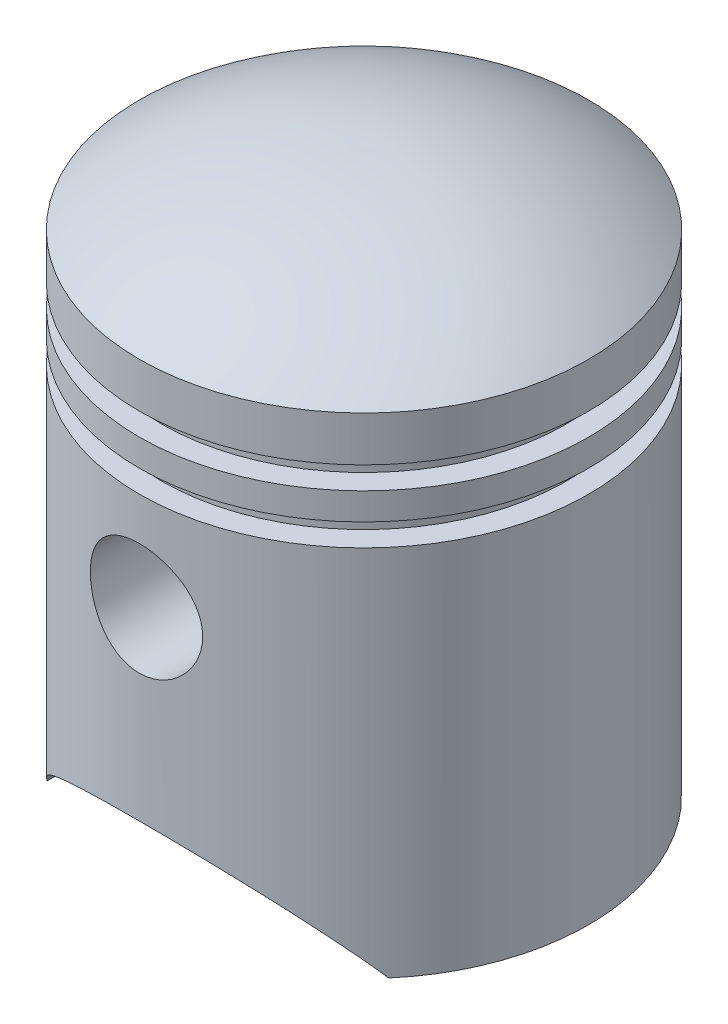
from build123d import *

# Parameters (mm, degrees)
SKETCH2_R               = 6.25
CUT_EXTRUDE1_DEPTH      = 26.0000001
CUT_EXTRUDE1_DEPTH_BACK = 26.0000001
BOSS_EXTRUDE2_START     = 12
SKETCH3_R               = 7.25
SKETCH3_R_2             = 6.25
BOSS_EXTRUDE2_DEPTH     = 11.925666


with BuildPart() as part:
    # Sketch1 → Revolve1 (revolve)
    with BuildSketch(Plane.XY):
        with BuildLine():
            Line((25, 0), (25, 41.5))
            Line((25, 41.5), (22.5, 41.5))
            Line((22.5, 41.5), (22.5, 44))
            Line((22.5, 44), (25, 44))
            Line((25, 44), (25, 47))
            Line((25, 47), (22.5, 47))
            Line((22.5, 47), (22.5, 49.5))
            Line((22.5, 49.5), (25, 49.5))
            Line((25, 49.5), (25, 54.5))
            ThreePointArc((25, 54.5), (13.174901691, 60.609067785), (0, 62.5))
            Line((0, 62.5), (0, 60.49936285))
            ThreePointArc((0, 60.49936285), (12.069492637, 58.859165445), (23, 53.484511145))
            Line((23, 53.484511145), (23, 51.5))
            Line((23, 51.5), (20.5, 51.5))
            Line((20.5, 51.5), (20.5, 45.5))
            Line((20.5, 45.5), (20.5, 39.5))
            Line((20.5, 39.5), (23, 39.5))
            Line((23, 39.5), (23, 0))
            Line((23, 0), (25, 0))
        make_face()
    revolve(axis=Axis((0, 62.5, 0), (0, -1, 0)))

    # Sketch2 → Cut-Extrude1 (cut, two sides)
    with BuildSketch(Plane.XY) as cut_extrude1_sk:
        with Locations((0, 30.5)):
            Circle(SKETCH2_R)
        with BuildLine():
            Line((-19, 0), (19, 0))
            ThreePointArc((19, 0), (0, 10), (-19, 0))
        make_face()
    extrude(amount=CUT_EXTRUDE1_DEPTH, mode=Mode.SUBTRACT)
    extrude(cut_extrude1_sk.sketch, amount=-CUT_EXTRUDE1_DEPTH_BACK, mode=Mode.SUBTRACT)

    # Sketch3 → Boss-Extrude2 (add)
    with BuildSketch(Plane.XY.offset(BOSS_EXTRUDE2_START)):
        with Locations((0, 30.5)):
            Circle(SKETCH3_R)
        with Locations((0, 30.5)):
            Circle(SKETCH3_R_2, mode=Mode.SUBTRACT)
    boss_extrude2 = extrude(amount=BOSS_EXTRUDE2_DEPTH)

    # Mirror1: Boss-Extrude2 across plane
    add(boss_extrude2.mirror(Plane.XY))


solid = part.part
